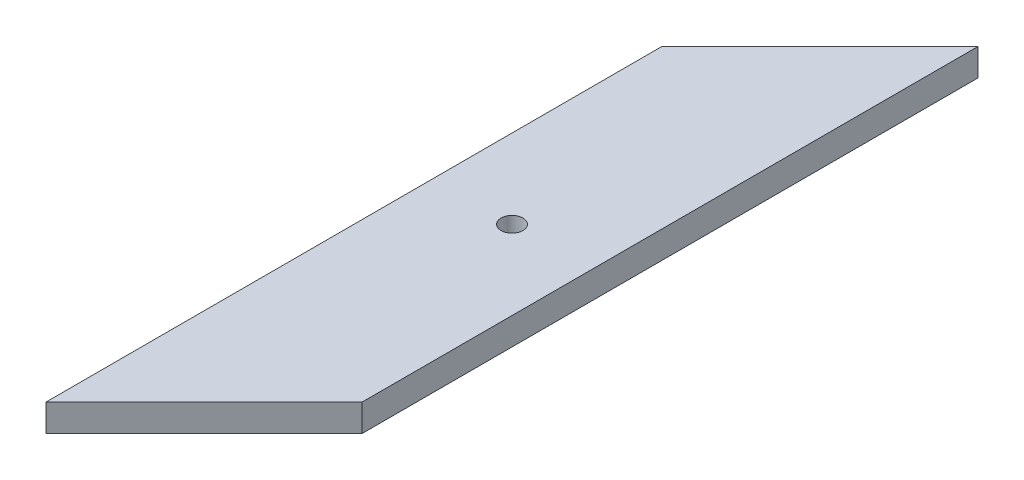
from build123d import *

# Parameters (mm, degrees)
SKETCH1_R           = 2
BOSS_EXTRUDE1_DEPTH = 5


with BuildPart() as part:
    # Sketch1 → Boss-Extrude1 (new body)
    with BuildSketch(Plane(origin=(0, 0, 0), x_dir=(1, 0, 0), z_dir=(0, 1, 0))):
        Polygon((-62.278471827, 53.688877211), (-91.278471827, 24.688877211), (-91.278471827, -88.311122789), (-62.278471827, -59.311122789), align=None)
        with Locations((-76.778471827, -17.311122789)):
            Circle(SKETCH1_R, mode=Mode.SUBTRACT)
    extrude(amount=BOSS_EXTRUDE1_DEPTH)


solid = part.part
